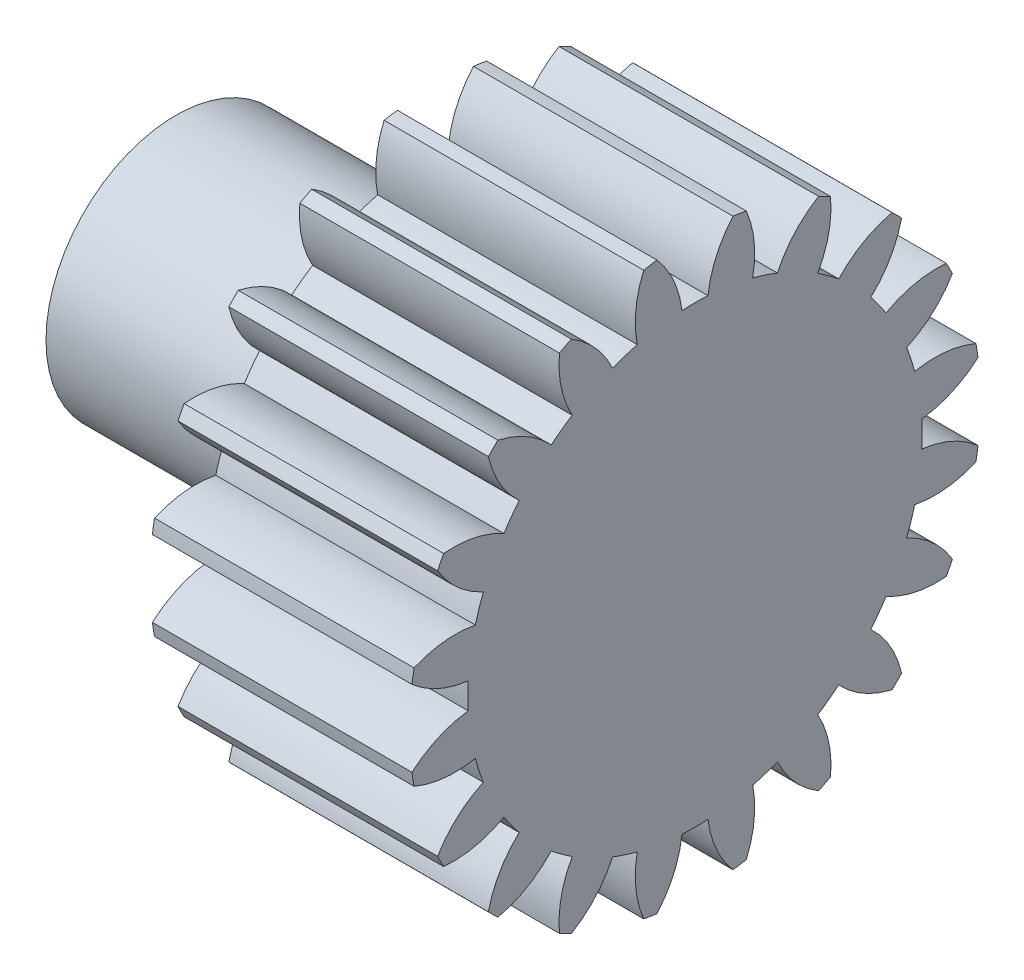
from build123d import *

# Parameters (mm, degrees)
BASPROSKE_W     = 10
BASPROSKE_H     = 11
TOOTHCUT_DEPTH  = 19.493242009
TEETHCUTS_COUNT = 20
TEETHCUTS_ANGLE = 342
BORSKE_R        = 0.5
BORE_DEPTH      = 50.0000508
SKETCH_1_R      = 5
EXTRUDE_1_DEPTH = 20


with BuildPart() as part:
    # BasProSke → Base-Revolve (revolve)
    with BuildSketch(Plane(origin=(0, 0, 0), x_dir=(1, 0, 0), z_dir=(0, 1, 0)), mode=Mode.PRIVATE) as base_revolve_sk:
        with Locations((5, 5.5)):
            Rectangle(BASPROSKE_W, BASPROSKE_H)
    revolve(base_revolve_sk.sketch.rotate(Axis((-10, 0, 0), (1, 0, 0)), 180), axis=Axis((-10, 0, 0), (1, 0, 0)))

    # TooCutSke → ToothCut (cut, through all)
    with BuildSketch(Plane(origin=(0, 0, 0), x_dir=(0, 0, -1), z_dir=(1, 0, 0))):
        with BuildLine():
            ThreePointArc((0.499924007, 8.734705318), (0, 8.749), (-0.499924007, 8.734705318))
            ThreePointArc((-0.499924007, 8.734705318), (-0.824302243, 9.905497836), (-1.485192705, 10.924909509))
            ThreePointArc((-1.485192705, 10.924909509), (0, 11.0254), (1.485192705, 10.924909509))
            ThreePointArc((1.485192705, 10.924909509), (0.824302243, 9.905497836), (0.499924007, 8.734705318))
        make_face()
    toothcut = extrude(amount=TOOTHCUT_DEPTH, mode=Mode.SUBTRACT)

    # TeethCuts: ToothCut ×20 about axis
    teethcuts_axis = Axis((-10, 0, 0), (1, 0, 0))
    for i in range(1, TEETHCUTS_COUNT):
        add(toothcut.rotate(teethcuts_axis, i * TEETHCUTS_ANGLE / (TEETHCUTS_COUNT - 1)), mode=Mode.SUBTRACT)

    # BorSke → Bore (cut, symmetric)
    with BuildSketch(Plane(origin=(0, 0, 0), x_dir=(0, 0, -1), z_dir=(1, 0, 0))):
        with Locations(Location((0, 0, 0), (0, 0, 180))):
            Circle(BORSKE_R)
    extrude(amount=BORE_DEPTH, both=True, mode=Mode.SUBTRACT)

    # 草图1 → 凸台-拉伸1 (add)
    with BuildSketch(Plane(origin=(10, 0, 0), x_dir=(0, 0, -1), z_dir=(1, 0, 0))):
        Circle(SKETCH_1_R)
    extrude(amount=-EXTRUDE_1_DEPTH)


solid = part.part
